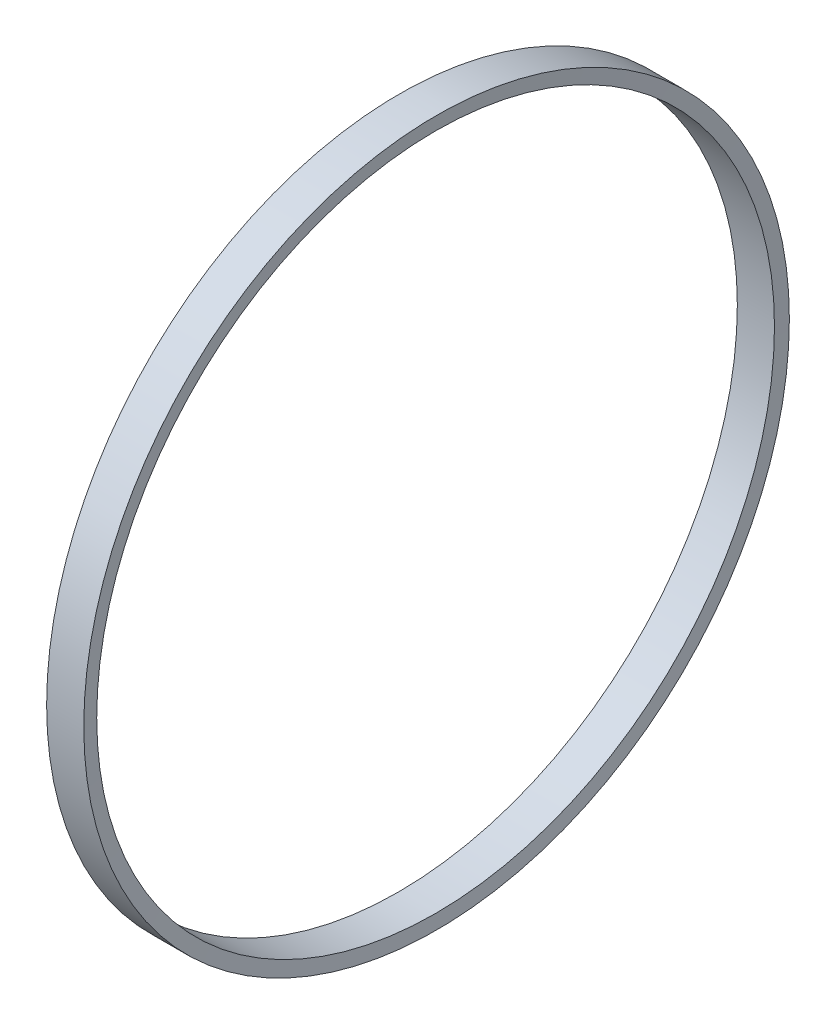
from build123d import *


with BuildPart() as part:
    # Skica2 → Rotovat1 (revolve)
    with BuildSketch(Plane.XY):
        Polygon((-15.678928865, 38), (-19.678928865, 38), (-19.783819083, 36.5), (-15.783819083, 36.5), align=None)
    revolve(axis=Axis((0, 0, 0), (-1, 0, 0)))


solid = part.part
